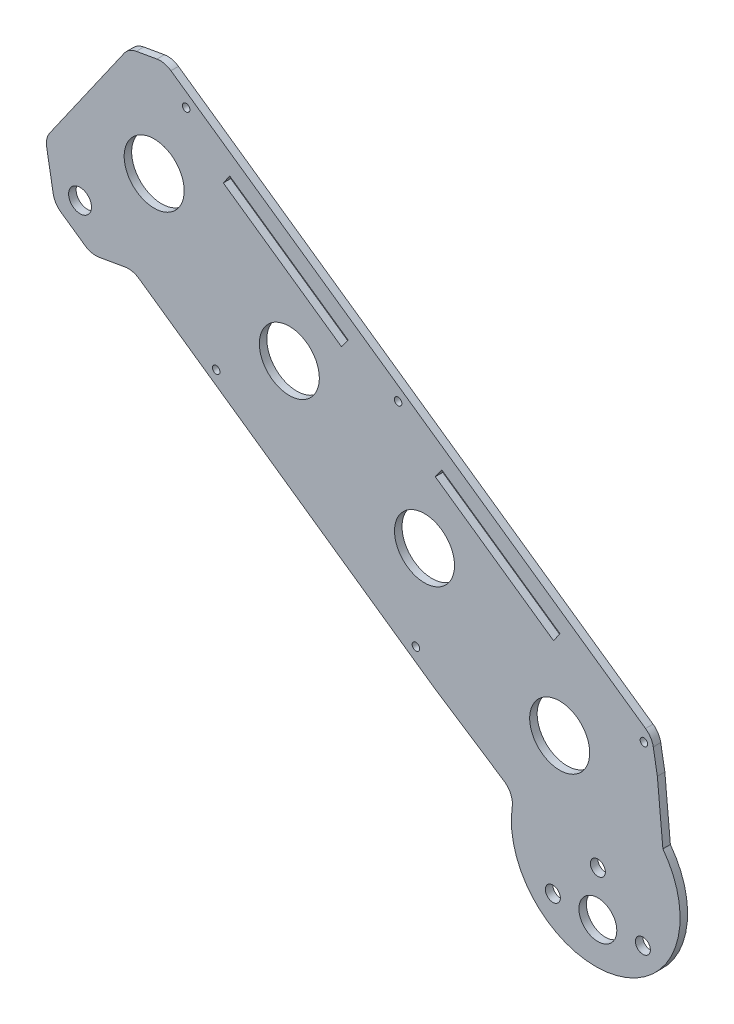
from build123d import *

# Parameters (mm, degrees)
SKETCH_1_R          = 5.05
SKETCH_1_R_2        = 3.05
EXTRUDE_1_DEPTH     = 2
SKETCH_4_R          = 8
CUT_EXTRUDE_2_DEPTH = 10
CHAMFER_4_SIZE      = 10
FILLET_1_R          = 5
SKETCH_5_R          = 2
CUT_EXTRUDE_3_DEPTH = 10
SKETCH_6_R          = 1
CUT_EXTRUDE_4_DEPTH = 10
CUT_EXTRUDE_5_DEPTH = 10
CUT_EXTRUDE_6_DEPTH = 3


with BuildPart() as part:
    # 草图1 → 凸台-拉伸1 (new body)
    with BuildSketch(Plane.XY):
        with BuildLine():
            Line((-58.561307239, 85.717685223), (-68.14143119, 84.029090729))
            Line((-68.14143119, 84.029090729), (-96.085099854, 44.126897339))
            Line((-96.085099854, 44.126897339), (-78.064572289, 31.507048438))
            Line((-78.064572289, 31.507048438), (-67.064872022, 33.445857727))
            Line((-67.064872022, 33.445857727), (32.399547585, -36.209480718))
            ThreePointArc((32.399547585, -36.209480718), (61.848825623, -67.605100723), (75.145579183, -26.664396317))
            Line((75.145579183, -26.664396317), (71.375998152, -5.277939337))
            Line((71.375998152, -5.277939337), (-58.561307239, 85.717685223))
        make_face()
        with Locations((56.971703287, -54.593433609)):
            Circle(SKETCH_1_R, mode=Mode.SUBTRACT)
        with Locations((-81.097830738, 42.429451993)):
            Circle(SKETCH_1_R_2, mode=Mode.SUBTRACT)
    extrude(amount=EXTRUDE_1_DEPTH)

    # 草图4 → 切除-拉伸2 (cut)
    with BuildSketch(Plane.XY.offset(2)):
        with Locations((-61.33373119, 58.54577073)):
            Circle(SKETCH_4_R)
        with Locations((-25.29267606, 33.306072927)):
            Circle(SKETCH_4_R)
        with Locations((10.74837907, 8.066375125)):
            Circle(SKETCH_4_R)
        with Locations((46.789434199, -17.173322677)):
            Circle(SKETCH_4_R)
    extrude(amount=-CUT_EXTRUDE_2_DEPTH, mode=Mode.SUBTRACT)

    # 倒角4
    chamfer_4_edges = [part.edges().sort_by_distance(p)[0] for p in [
        (-96.085099854, 44.126897339, 1),
    ]]
    chamfer(chamfer_4_edges, length=CHAMFER_4_SIZE)

    # 圆角1
    fillet_1_edges = [part.edges().sort_by_distance(p)[0] for p in [
        (-68.14143119, 84.029090729, 1),
        (-58.561307239, 85.717685223, 1),
        (71.375998152, -5.277939337, 1),
        (32.399547585, -36.209480718, 1),
        (-67.064872022, 33.445857727, 1),
        (-78.064572289, 31.507048438, 1),
        (-87.893950961, 38.390602384, 1),
        (-90.348804899, 52.318046232, 1),
    ]]
    fillet(fillet_1_edges, radius=FILLET_1_R)

    # 草图5 → 切除-拉伸3 (cut)
    with BuildSketch(Plane(origin=(0, 0, 0), x_dir=(-1, 0, 0), z_dir=(0, 0, -1))):
        with Locations((-56.971703287, -42.593433609)):
            Circle(SKETCH_5_R)
        with Locations((-44.971703287, -54.593433609)):
            Circle(SKETCH_5_R)
        with Locations((-68.971703287, -54.593433609)):
            Circle(SKETCH_5_R)
    extrude(amount=-CUT_EXTRUDE_3_DEPTH, mode=Mode.SUBTRACT)

    # 草图6 → 切除-拉伸4 (cut)
    with BuildSketch(Plane.XY.offset(2)):
        with Locations((-52.81071672, 78.028033355)):
            Circle(SKETCH_6_R)
        with Locations((3.708210642, 38.447598165)):
            Circle(SKETCH_6_R)
        with Locations((69.237401787, -7.442761475)):
            Circle(SKETCH_6_R)
        with Locations((-44.782446967, 21.503874532)):
            Circle(SKETCH_6_R)
        with Locations((8.460020838, -15.782042676)):
            Circle(SKETCH_6_R)
    extrude(amount=-CUT_EXTRUDE_4_DEPTH, mode=Mode.SUBTRACT)

    # 草图7 → 切除-拉伸5 (cut)
    with BuildSketch(Plane(origin=(0, 0, 0), x_dir=(-1, 0, 0), z_dir=(0, 0, -1))):
        Polygon((42.900547388, 65.594166547), (11.364624149, 43.50943097), (9.643735663, 45.966775638), (41.179658901, 68.051511215), align=None)
        Polygon((-45.154303213, 3.92899578), (-13.618379974, 26.013731357), (-15.339268461, 28.471076025), (-46.875191699, 6.386340448), align=None)
    extrude(amount=-CUT_EXTRUDE_5_DEPTH, mode=Mode.SUBTRACT)

    # 草图8 → 切除-拉伸6 (cut, through all)
    with BuildSketch(Plane.XY.offset(2)):
        with BuildLine():
            Line((31.929922098, -35.060209846), (13.483519413, -22.962509091))
            Line((13.483519413, -22.962509091), (28.325536176, -95.018326982))
            Line((28.325536176, -95.018326982), (121.098918435, -54.025437146))
            Line((121.098918435, -54.025437146), (72.832718458, -13.542541133))
            Line((72.832718458, -13.542541133), (74.305789634, -29.580542184))
            ThreePointArc((74.305789634, -29.580542184), (62.030487783, -64.990252685), (34.135631, -39.96211655))
            ThreePointArc((34.135631, -39.96211655), (33.747527426, -37.189547046), (31.929922098, -35.060209846))
        make_face()
    extrude(amount=-CUT_EXTRUDE_6_DEPTH, mode=Mode.SUBTRACT)


solid = part.part
